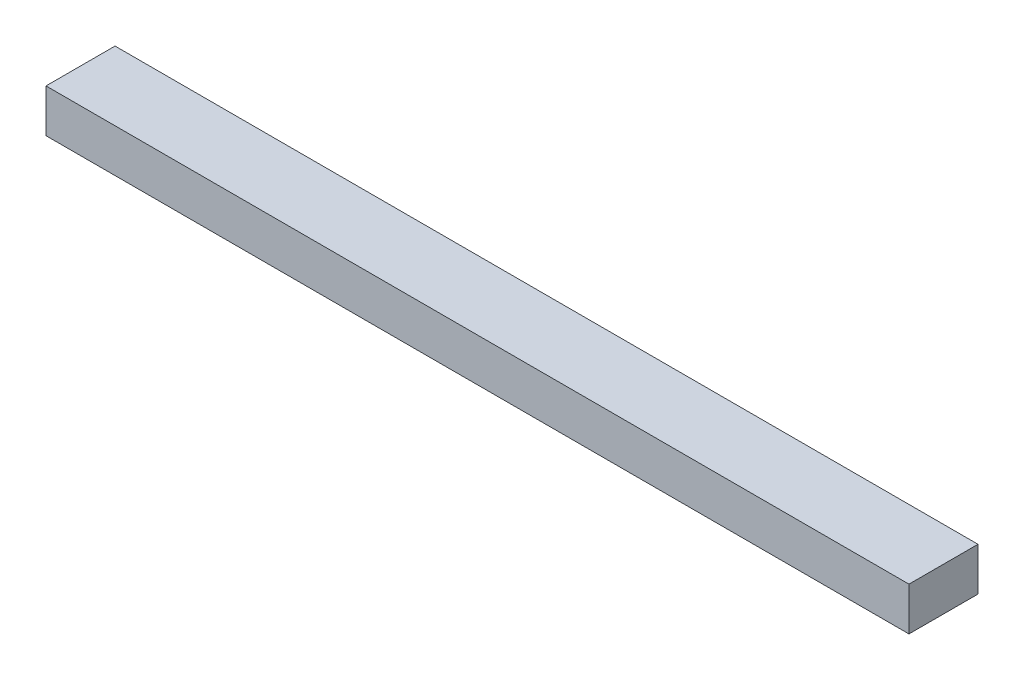
from build123d import *

# Parameters (mm, degrees)
SKETCH_1_W      = 1000
SKETCH_1_H      = 80
EXTRUDE_1_DEPTH = 50


with BuildPart() as part:
    # ｽｹｯﾁ1 → ﾎﾞｽ - 押し出し1 (new body)
    with BuildSketch(Plane(origin=(0, 0, 0), x_dir=(1, 0, 0), z_dir=(0, 1, 0))):
        Rectangle(SKETCH_1_W, SKETCH_1_H)
    extrude(amount=EXTRUDE_1_DEPTH)


solid = part.part
